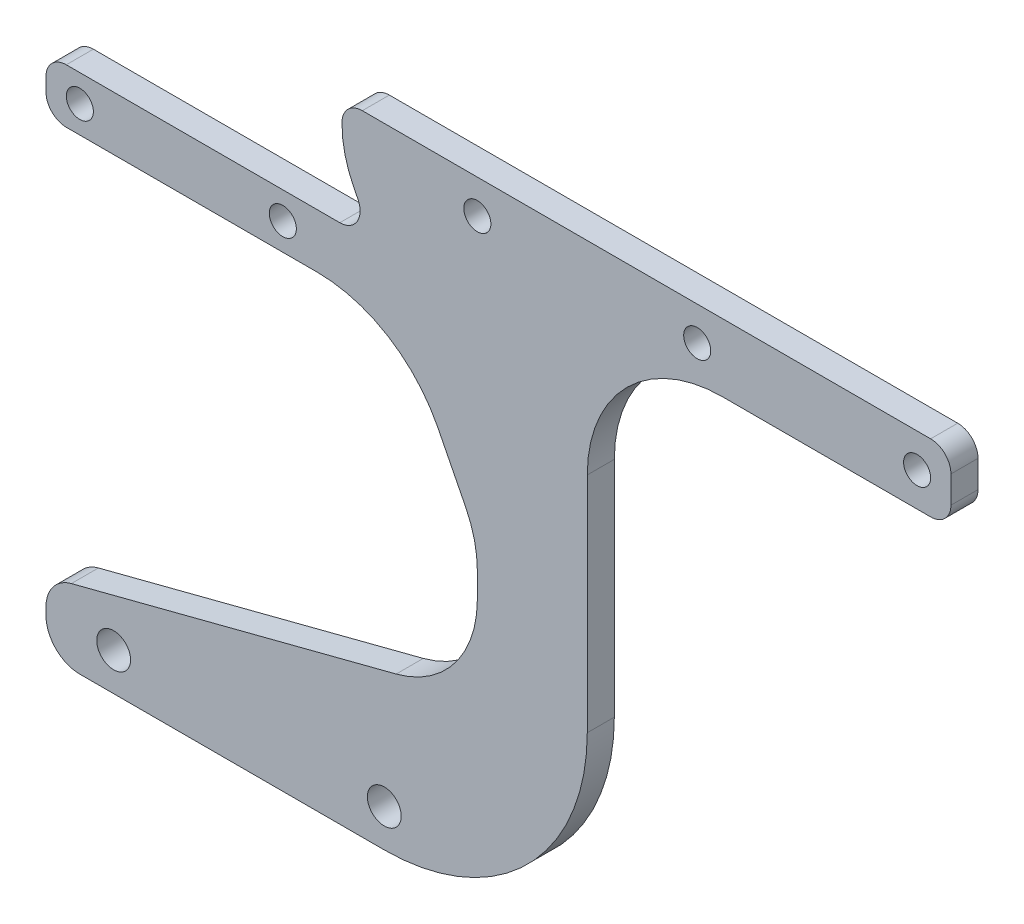
from build123d import *

# Parameters (mm, degrees)
SKETCH1_R           = 2.001
SKETCH1_R_2         = 2.5
SKETCH1_R_3         = 2
BOSS_EXTRUDE2_DEPTH = 4


with BuildPart() as part:
    # Sketch1 → Boss-Extrude2 (new body)
    with BuildSketch(Plane.XY):
        with BuildLine():
            Line((249.889094902, -24.965497133), (254.003864049, -33.092166198))
            ThreePointArc((254.003864049, -33.092166198), (255.292000843, -36.604410668), (255.729349518, -40.319768492))
            Line((255.729349518, -40.319768492), (255.729349518, -44.113946135))
            ThreePointArc((255.729349518, -44.113946135), (252.381328024, -53.908201589), (243.738419531, -59.60353482))
            Line((243.738419531, -59.60353482), (195.72651514, -72.030145369))
            ThreePointArc((195.72651514, -72.030145369), (193.025606236, -73.809937003), (191.979349518, -76.870641833))
            Line((191.979349518, -76.870641833), (191.979349518, -78))
            ThreePointArc((191.979349518, -78), (193.443815613, -81.535533906), (196.979349518, -83))
            Line((196.979349518, -83), (241.979349518, -83))
            ThreePointArc((241.979349518, -83), (263.192552954, -74.213203436), (271.979349518, -53))
            Line((271.979349518, -53), (271.979349518, -20))
            ThreePointArc((271.979349518, -20), (277.837213895, -5.857864376), (291.979349518, 0))
            Line((291.979349518, 0), (322.729349518, 0))
            ThreePointArc((322.729349518, 0), (324.850669862, 0.878679656), (325.729349518, 3))
            Line((325.729349518, 3), (325.729349518, 7))
            ThreePointArc((325.729349518, 7), (324.850669862, 9.121320344), (322.729349518, 10))
            Line((322.729349518, 10), (238.729349518, 10))
            ThreePointArc((238.729349518, 10), (236.608029175, 9.121320344), (235.729349518, 7))
            Line((235.729349518, 7), (235.729349518, 6.819768492))
            ThreePointArc((235.729349518, 6.819768492), (236.166698194, 3.104410668), (237.454834988, -0.407833802))
            Line((237.454834988, -0.407833802), (238.081894478, -1.646276295))
            ThreePointArc((238.081894478, -1.646276295), (237.961390247, -4.571220464), (235.406315161, -6))
            Line((235.406315161, -6), (194.978349518, -6))
            ThreePointArc((194.978349518, -6), (192.857736282, -6.878386763), (191.979349518, -8.999))
            Line((191.979349518, -8.999), (191.979349518, -11.001))
            ThreePointArc((191.979349518, -11.001), (192.857736282, -13.121613237), (194.978349518, -14))
            Line((194.978349518, -14), (232.045951739, -14))
            ThreePointArc((232.045951739, -14), (242.517578705, -16.960486255), (249.889094902, -24.965497133))
        make_face()
        with Locations((226.979349518, -10)):
            Circle(SKETCH1_R, mode=Mode.SUBTRACT)
        with Locations((196.979349518, -10)):
            Circle(SKETCH1_R, mode=Mode.SUBTRACT)
        with Locations((201.979349518, -77.435320916)):
            Circle(SKETCH1_R_2, mode=Mode.SUBTRACT)
        with Locations((241.979349518, -77.435320916)):
            Circle(SKETCH1_R_2, mode=Mode.SUBTRACT)
        with Locations((255.729349518, 5)):
            Circle(SKETCH1_R_3, mode=Mode.SUBTRACT)
        with Locations((288.229349518, 5)):
            Circle(SKETCH1_R_3, mode=Mode.SUBTRACT)
        with Locations((320.729349518, 5)):
            Circle(SKETCH1_R_3, mode=Mode.SUBTRACT)
    extrude(amount=BOSS_EXTRUDE2_DEPTH)


solid = part.part
